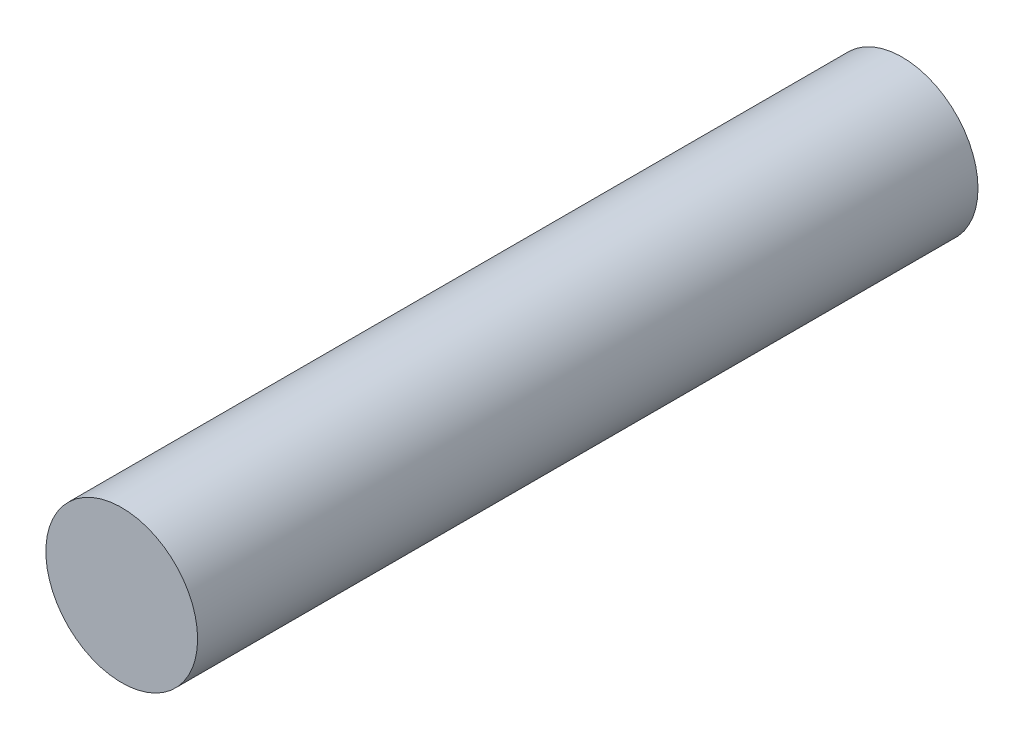
from build123d import *

# Parameters (mm, degrees)
CROQUIS1_R              = 3.5
SALIENTE_EXTRUIR1_DEPTH = 36


with BuildPart() as part:
    # Croquis1 → Saliente-Extruir1 (new body)
    with BuildSketch(Plane.XY):
        Circle(CROQUIS1_R)
    extrude(amount=SALIENTE_EXTRUIR1_DEPTH)


solid = part.part
